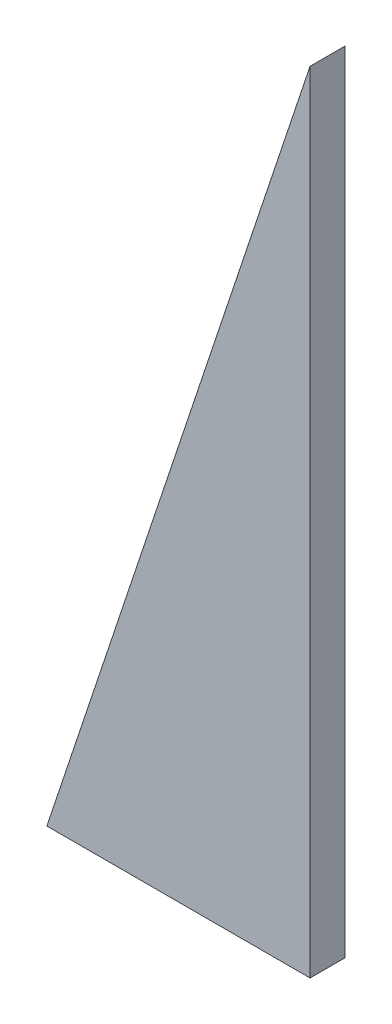
from build123d import *

# Parameters (mm, degrees)
BOSS_EXTRUDE1_DEPTH = 4


with BuildPart() as part:
    # Sketch1 → Boss-Extrude1 (new body, symmetric)
    with BuildSketch(Plane.XY):
        Polygon((0, 0), (0, 180), (-60, 0), align=None)
    extrude(amount=BOSS_EXTRUDE1_DEPTH, both=True)


solid = part.part
